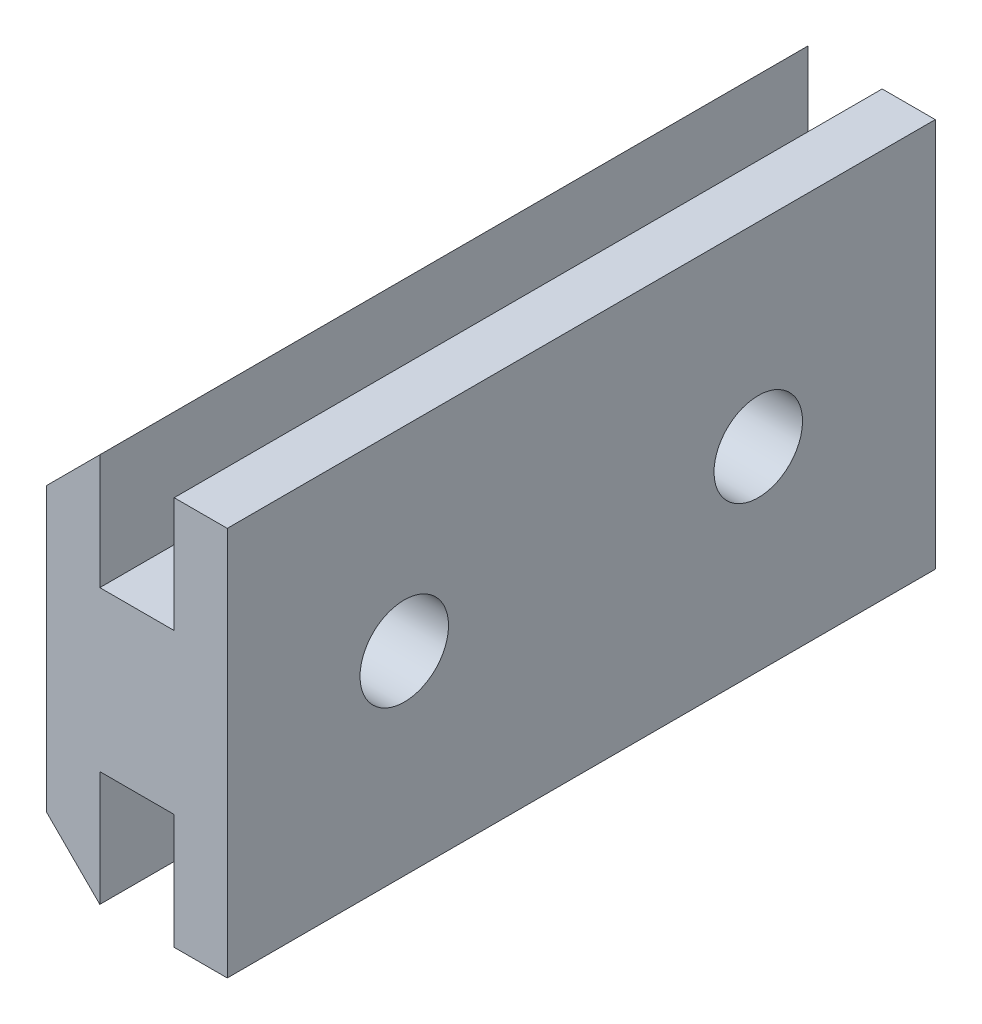
from build123d import *

# Parameters (mm, degrees)
BOSS_EXTRU_1_DEPTH      = 20
ESQUISSE1_R             = 1.25
ENL_V_MAT_EXTRU_1_DEPTH = 6.1


with BuildPart() as part:
    # ProfileRainureEsquisse → Boss.-Extru.1 (new body)
    with BuildSketch(Plane.XY):
        Polygon((0.1, -1.75), (0.1, 6.25), (1.6, 7.75), (1.6, 4.5), (3.7, 4.5), (3.7, 7.75), (5.2, 7.75), (5.2, -3.25), (3.7, -3.25), (3.7, 0), (1.6, 0), (1.6, -3.25), align=None)
    extrude(amount=BOSS_EXTRU_1_DEPTH)

    # Esquisse1 → Enlèv. mat.-Extru.1 (cut, through all)
    with BuildSketch(Plane(origin=(5.2, 0, 0), x_dir=(0, 0, -1), z_dir=(1, 0, 0))):
        with Locations((-15, 2.25)):
            Circle(ESQUISSE1_R)
        with Locations((-5, 2.25)):
            Circle(ESQUISSE1_R)
    extrude(amount=-ENL_V_MAT_EXTRU_1_DEPTH, mode=Mode.SUBTRACT)


solid = part.part
